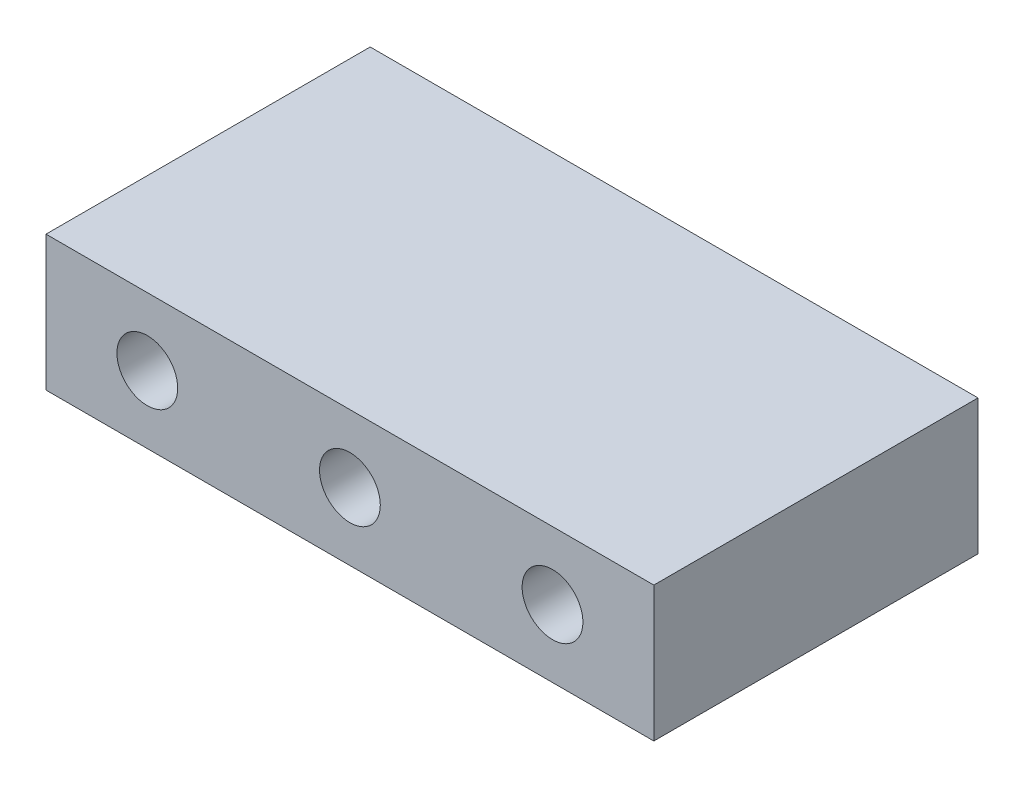
from build123d import *

# Parameters (mm, degrees)
SKETCH_1_W      = 90
SKETCH_1_H      = 20
SKETCH_1_R      = 4.5
EXTRUDE_1_DEPTH = 48


with BuildPart() as part:
    # 草图1 → 凸台-拉伸1 (new body)
    with BuildSketch(Plane.XY):
        Rectangle(SKETCH_1_W, SKETCH_1_H)
        with Locations((-30, 0)):
            Circle(SKETCH_1_R, mode=Mode.SUBTRACT)
        Circle(SKETCH_1_R, mode=Mode.SUBTRACT)
        with Locations((30, 0)):
            Circle(SKETCH_1_R, mode=Mode.SUBTRACT)
    extrude(amount=EXTRUDE_1_DEPTH)


solid = part.part
